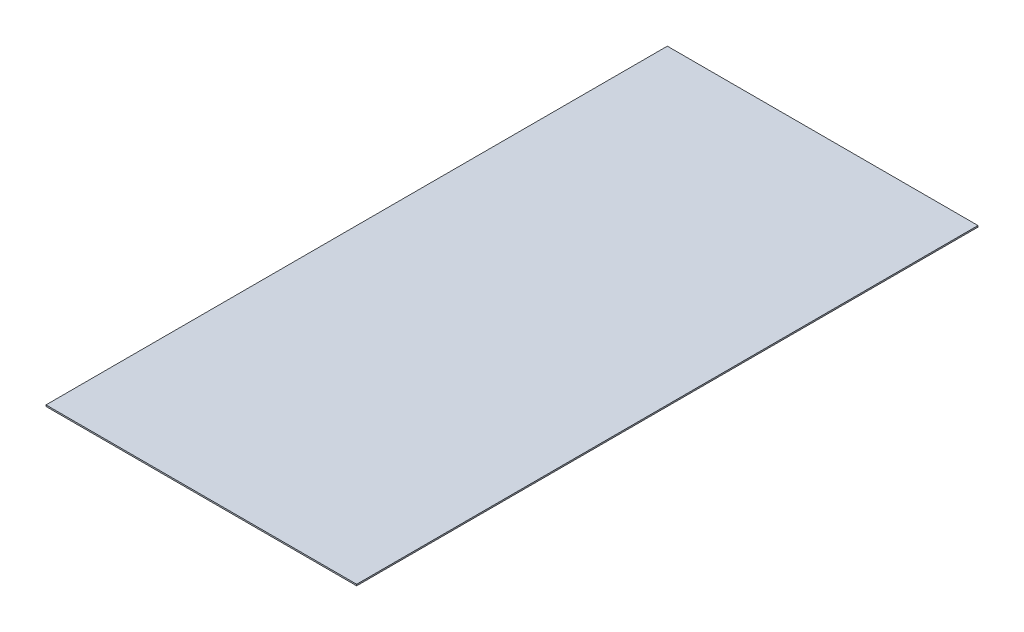
from build123d import *

# Parameters (mm, degrees)
SKETCH1_W           = 1219.2
SKETCH1_H           = 2438.4
BOSS_EXTRUDE1_DEPTH = 5.55625


with BuildPart() as part:
    # Sketch1 → Boss-Extrude1 (new body)
    with BuildSketch(Plane(origin=(0, 0, 0), x_dir=(1, 0, 0), z_dir=(0, 1, 0))):
        Rectangle(SKETCH1_W, SKETCH1_H)
    extrude(amount=BOSS_EXTRUDE1_DEPTH)


solid = part.part
